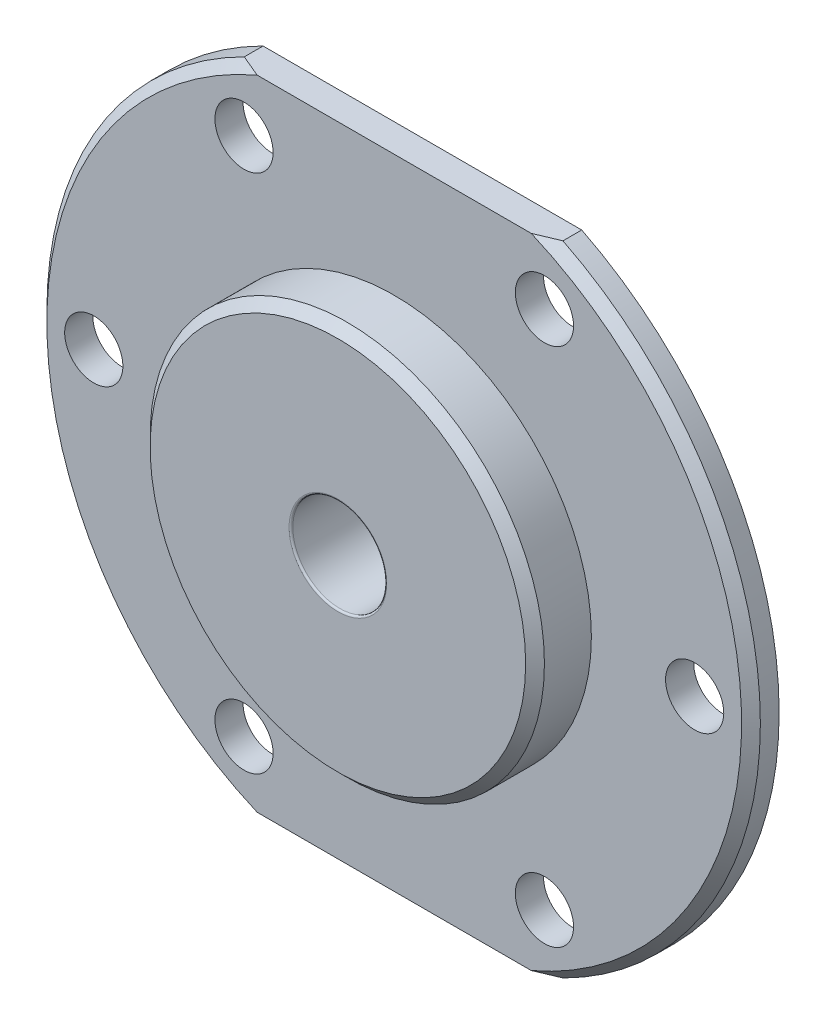
from build123d import *

# Parameters (mm, degrees)
SKETCH1_R           = 19
BOSS_EXTRUDE2_DEPTH = 1.5
SKETCH2_R           = 1.55
CUT_EXTRUDE1_DEPTH  = 6.5
SKETCH3_R           = 10.5
BOSS_EXTRUDE3_DEPTH = 3
SKETCH4_R           = 5
BOSS_EXTRUDE4_DEPTH = 5
SKETCH5_R           = 2.5
CUT_EXTRUDE2_DEPTH  = 28.207535721
CHAMFER1_SIZE       = 0.5
FILLET1_R           = 0.1


with BuildPart() as part:
    # Sketch1 → Boss-Extrude2 (new body)
    with BuildSketch(Plane.XY):
        Circle(SKETCH1_R)
    extrude(amount=BOSS_EXTRUDE2_DEPTH)

    # Sketch2 → Cut-Extrude1 (cut)
    with BuildSketch(Plane.XY.offset(1.5)):
        with BuildLine():
            ThreePointArc((8.485281374, 17), (0, 19), (-8.485281374, 17))
            Line((-8.485281374, 17), (8.485281374, 17))
        make_face()
        with BuildLine():
            Line((8.485281374, -17), (-8.485281374, -17))
            ThreePointArc((-8.485281374, -17), (0, -19), (8.485281374, -17))
        make_face()
        with Locations((-8, 13.856406461)):
            Circle(SKETCH2_R)
        with Locations((8, 13.856406461)):
            Circle(SKETCH2_R)
        with Locations((16, 0)):
            Circle(SKETCH2_R)
        with Locations((8, -13.856406461)):
            Circle(SKETCH2_R)
        with Locations((-8, -13.856406461)):
            Circle(SKETCH2_R)
        with Locations((-16, 0)):
            Circle(SKETCH2_R)
    extrude(amount=-CUT_EXTRUDE1_DEPTH, mode=Mode.SUBTRACT)

    # Sketch3 → Boss-Extrude3 (add)
    with BuildSketch(Plane.XY.offset(1.5)):
        Circle(SKETCH3_R)
    extrude(amount=BOSS_EXTRUDE3_DEPTH)

    # Sketch4 → Boss-Extrude4 (add)
    with BuildSketch(Plane(origin=(0, 0, 0), x_dir=(-1, 0, 0), z_dir=(0, 0, -1))):
        with Locations(Location((0, 0, 0), (0, 0, 180))):
            Circle(SKETCH4_R)
    extrude(amount=BOSS_EXTRUDE4_DEPTH)

    # Sketch5 → Cut-Extrude2 (cut, through all)
    with BuildSketch(Plane.XY.offset(4.5)):
        Circle(SKETCH5_R)
    extrude(amount=-CUT_EXTRUDE2_DEPTH, mode=Mode.SUBTRACT)

    # Chamfer1
    chamfer1_edges = [part.edges().sort_by_distance(p)[0] for p in [
        (-19, 0, 1.5),
        (19, 0, 1.5),
        (-10.5, 0, 4.5),
        (-5, 0, -5),
    ]]
    chamfer(chamfer1_edges, length=CHAMFER1_SIZE)

    # Fillet1
    fillet1_edges = [part.edges().sort_by_distance(p)[0] for p in [
        (-2.5, 0, -5),
        (-2.5, 0, 4.5),
    ]]
    fillet(fillet1_edges, radius=FILLET1_R)


solid = part.part
